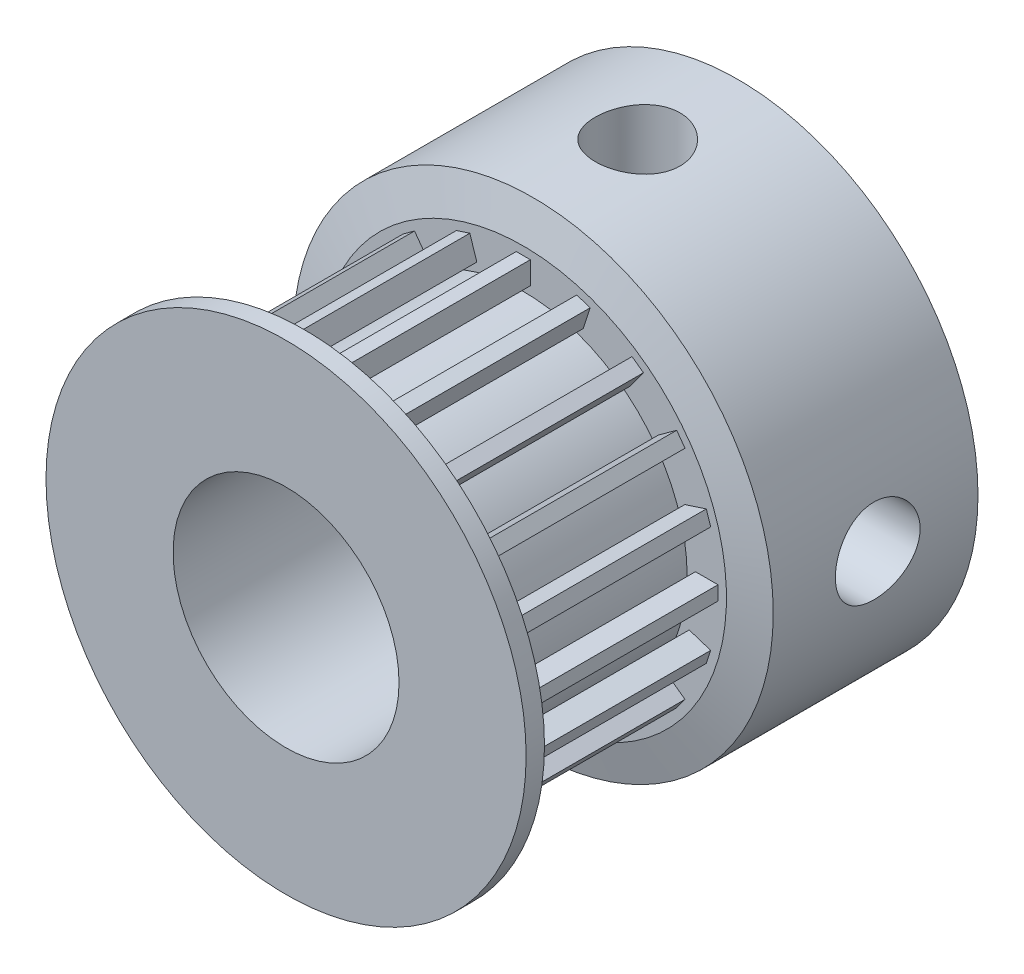
from build123d import *

# Parameters (mm, degrees)
CHAMFER1_SIZE       = 0.35
CHAMFER1_SIZE2      = 1.306217783
CHAMFER2_SIZE       = 0.35
CHAMFER2_SIZE2      = 1.306217783
BOSS_EXTRUDE1_DEPTH = 7.4
SKETCH6_R           = 1.5
CUT_EXTRUDE1_DEPTH  = 10
CIRPATTERN1_COUNT   = 2
CIRPATTERN1_ANGLE   = 270


with BuildPart() as part:
    # Sketch2 → Revolve1 (revolve)
    with BuildSketch(Plane(origin=(0, 0, 0), x_dir=(0, 0, -1), z_dir=(1, 0, 0))):
        Polygon((-16, 4), (0, 4), (0, 8.5), (-7.6, 8.5), (-7.6, 5.8), (-15, 5.8), (-15, 8.5), (-16, 8.5), align=None)
    revolve(axis=Axis((0, 0, 79.609460318), (0, 0, -1)))

    # Chamfer1
    chamfer1_edges = [part.edges().sort_by_distance(p)[0] for p in [
        (0, -8.5, 15),
    ]]
    chamfer1_side = [part.faces().sort_by_distance(p)[0] for p in [
        (0, -8.5, 15.5),
    ]]
    chamfer(chamfer1_edges, length=CHAMFER1_SIZE, length2=CHAMFER1_SIZE2, reference=chamfer1_side[0])

    # Chamfer2
    chamfer2_edges = [part.edges().sort_by_distance(p)[0] for p in [
        (0, -8.5, 7.6),
    ]]
    chamfer2_side = [part.faces().sort_by_distance(p)[0] for p in [
        (0, -8.5, 3.8),
    ]]
    chamfer(chamfer2_edges, length=CHAMFER2_SIZE, length2=CHAMFER2_SIZE2, reference=chamfer2_side[0])

    # Sketch4 → Boss-Extrude1 (add)
    with BuildSketch(Plane.XY.offset(7.6)):
        with BuildLine():
            Line((1.645655792, 5.873824735), (1.892869388, 6.634669948))
            Line((1.892869388, 6.634669948), (2.368397646, 6.48016145))
            Line((2.368397646, 6.48016145), (2.121184051, 5.719316237))
            ThreePointArc((2.121184051, 5.719316237), (1.885003666, 5.801444749), (1.645655792, 5.873824735))
        make_face()
        with BuildLine():
            Line((-0.25, 6.094874896), (-0.25, 6.894874896))
            Line((-0.25, 6.894874896), (0.25, 6.894874896))
            Line((0.25, 6.894874896), (0.25, 6.094874896))
            ThreePointArc((0.25, 6.094874896), (0, 6.1), (-0.25, 6.094874896))
        make_face()
        with BuildLine():
            Line((3.38022333, 5.077803683), (3.850451532, 5.725017278))
            Line((3.850451532, 5.725017278), (4.254960029, 5.431124652))
            Line((4.254960029, 5.431124652), (3.784731827, 4.783911057))
            ThreePointArc((3.784731827, 4.783911057), (3.585490039, 4.935003666), (3.38022333, 5.077803683))
        make_face()
        with BuildLine():
            Line((4.783911057, 3.784731827), (5.431124652, 4.254960029))
            Line((5.431124652, 4.254960029), (5.725017278, 3.850451532))
            Line((5.725017278, 3.850451532), (5.077803683, 3.38022333))
            ThreePointArc((5.077803683, 3.38022333), (4.935003666, 3.585490039), (4.783911057, 3.784731827))
        make_face()
        with BuildLine():
            Line((5.719316237, 2.121184051), (6.48016145, 2.368397646))
            Line((6.48016145, 2.368397646), (6.634669948, 1.892869388))
            Line((6.634669948, 1.892869388), (5.873824735, 1.645655792))
            ThreePointArc((5.873824735, 1.645655792), (5.801444749, 1.885003666), (5.719316237, 2.121184051))
        make_face()
        with BuildLine():
            Line((6.094874896, 0.25), (6.894874896, 0.25))
            Line((6.894874896, 0.25), (6.894874896, -0.25))
            Line((6.894874896, -0.25), (6.094874896, -0.25))
            ThreePointArc((6.094874896, -0.25), (6.1, 0), (6.094874896, 0.25))
        make_face()
        with BuildLine():
            Line((5.873824735, -1.645655792), (6.634669948, -1.892869388))
            Line((6.634669948, -1.892869388), (6.48016145, -2.368397646))
            Line((6.48016145, -2.368397646), (5.719316237, -2.121184051))
            ThreePointArc((5.719316237, -2.121184051), (5.801444749, -1.885003666), (5.873824735, -1.645655792))
        make_face()
        with BuildLine():
            Line((5.077803683, -3.38022333), (5.725017278, -3.850451532))
            Line((5.725017278, -3.850451532), (5.431124652, -4.254960029))
            Line((5.431124652, -4.254960029), (4.783911057, -3.784731827))
            ThreePointArc((4.783911057, -3.784731827), (4.935003666, -3.585490039), (5.077803683, -3.38022333))
        make_face()
        with BuildLine():
            Line((3.784731827, -4.783911057), (4.254960029, -5.431124652))
            Line((4.254960029, -5.431124652), (3.850451532, -5.725017278))
            Line((3.850451532, -5.725017278), (3.38022333, -5.077803683))
            ThreePointArc((3.38022333, -5.077803683), (3.585490039, -4.935003666), (3.784731827, -4.783911057))
        make_face()
        with BuildLine():
            Line((2.121184051, -5.719316237), (2.368397646, -6.48016145))
            Line((2.368397646, -6.48016145), (1.892869388, -6.634669948))
            Line((1.892869388, -6.634669948), (1.645655792, -5.873824735))
            ThreePointArc((1.645655792, -5.873824735), (1.885003666, -5.801444749), (2.121184051, -5.719316237))
        make_face()
        with BuildLine():
            Line((0.25, -6.094874896), (0.25, -6.894874896))
            Line((0.25, -6.894874896), (-0.25, -6.894874896))
            Line((-0.25, -6.894874896), (-0.25, -6.094874896))
            ThreePointArc((-0.25, -6.094874896), (0, -6.1), (0.25, -6.094874896))
        make_face()
        with BuildLine():
            Line((-1.645655792, -5.873824735), (-1.892869388, -6.634669948))
            Line((-1.892869388, -6.634669948), (-2.368397646, -6.48016145))
            Line((-2.368397646, -6.48016145), (-2.121184051, -5.719316237))
            ThreePointArc((-2.121184051, -5.719316237), (-1.885003666, -5.801444749), (-1.645655792, -5.873824735))
        make_face()
        with BuildLine():
            Line((-3.38022333, -5.077803683), (-3.850451532, -5.725017278))
            Line((-3.850451532, -5.725017278), (-4.254960029, -5.431124652))
            Line((-4.254960029, -5.431124652), (-3.784731827, -4.783911057))
            ThreePointArc((-3.784731827, -4.783911057), (-3.585490039, -4.935003666), (-3.38022333, -5.077803683))
        make_face()
        with BuildLine():
            Line((-4.783911057, -3.784731827), (-5.431124652, -4.254960029))
            Line((-5.431124652, -4.254960029), (-5.725017278, -3.850451532))
            Line((-5.725017278, -3.850451532), (-5.077803683, -3.38022333))
            ThreePointArc((-5.077803683, -3.38022333), (-4.935003666, -3.585490039), (-4.783911057, -3.784731827))
        make_face()
        with BuildLine():
            Line((-5.719316237, -2.121184051), (-6.48016145, -2.368397646))
            Line((-6.48016145, -2.368397646), (-6.634669948, -1.892869388))
            Line((-6.634669948, -1.892869388), (-5.873824735, -1.645655792))
            ThreePointArc((-5.873824735, -1.645655792), (-5.801444749, -1.885003666), (-5.719316237, -2.121184051))
        make_face()
        with BuildLine():
            Line((-6.094874896, -0.25), (-6.894874896, -0.25))
            Line((-6.894874896, -0.25), (-6.894874896, 0.25))
            Line((-6.894874896, 0.25), (-6.094874896, 0.25))
            ThreePointArc((-6.094874896, 0.25), (-6.1, 0), (-6.094874896, -0.25))
        make_face()
        with BuildLine():
            Line((-5.873824735, 1.645655792), (-6.634669948, 1.892869388))
            Line((-6.634669948, 1.892869388), (-6.48016145, 2.368397646))
            Line((-6.48016145, 2.368397646), (-5.719316237, 2.121184051))
            ThreePointArc((-5.719316237, 2.121184051), (-5.801444749, 1.885003666), (-5.873824735, 1.645655792))
        make_face()
        with BuildLine():
            Line((-5.077803683, 3.38022333), (-5.725017278, 3.850451532))
            Line((-5.725017278, 3.850451532), (-5.431124652, 4.254960029))
            Line((-5.431124652, 4.254960029), (-4.783911057, 3.784731827))
            ThreePointArc((-4.783911057, 3.784731827), (-4.935003666, 3.585490039), (-5.077803683, 3.38022333))
        make_face()
        with BuildLine():
            Line((-3.784731827, 4.783911057), (-4.254960029, 5.431124652))
            Line((-4.254960029, 5.431124652), (-3.850451532, 5.725017278))
            Line((-3.850451532, 5.725017278), (-3.38022333, 5.077803683))
            ThreePointArc((-3.38022333, 5.077803683), (-3.585490039, 4.935003666), (-3.784731827, 4.783911057))
        make_face()
        with BuildLine():
            Line((-2.121184051, 5.719316237), (-2.368397646, 6.48016145))
            Line((-2.368397646, 6.48016145), (-1.892869388, 6.634669948))
            Line((-1.892869388, 6.634669948), (-1.645655792, 5.873824735))
            ThreePointArc((-1.645655792, 5.873824735), (-1.885003666, 5.801444749), (-2.121184051, 5.719316237))
        make_face()
    extrude(amount=BOSS_EXTRUDE1_DEPTH)

    # Sketch6 → Cut-Extrude1 (cut)
    with BuildSketch(Plane(origin=(0, 8.9, 0), x_dir=(-1, 0, 0), z_dir=(0, 1, 0))):
        with Locations((0, 3.55)):
            Circle(SKETCH6_R)
    cut_extrude1 = extrude(amount=-CUT_EXTRUDE1_DEPTH, mode=Mode.SUBTRACT)

    # CirPattern1: Cut-Extrude1 ×2 about axis
    cirpattern1_axis = Axis((0, 0, 0), (0, 0, 1))
    for i in range(1, CIRPATTERN1_COUNT):
        add(cut_extrude1.rotate(cirpattern1_axis, i * CIRPATTERN1_ANGLE / (CIRPATTERN1_COUNT - 1)), mode=Mode.SUBTRACT)


solid = part.part
